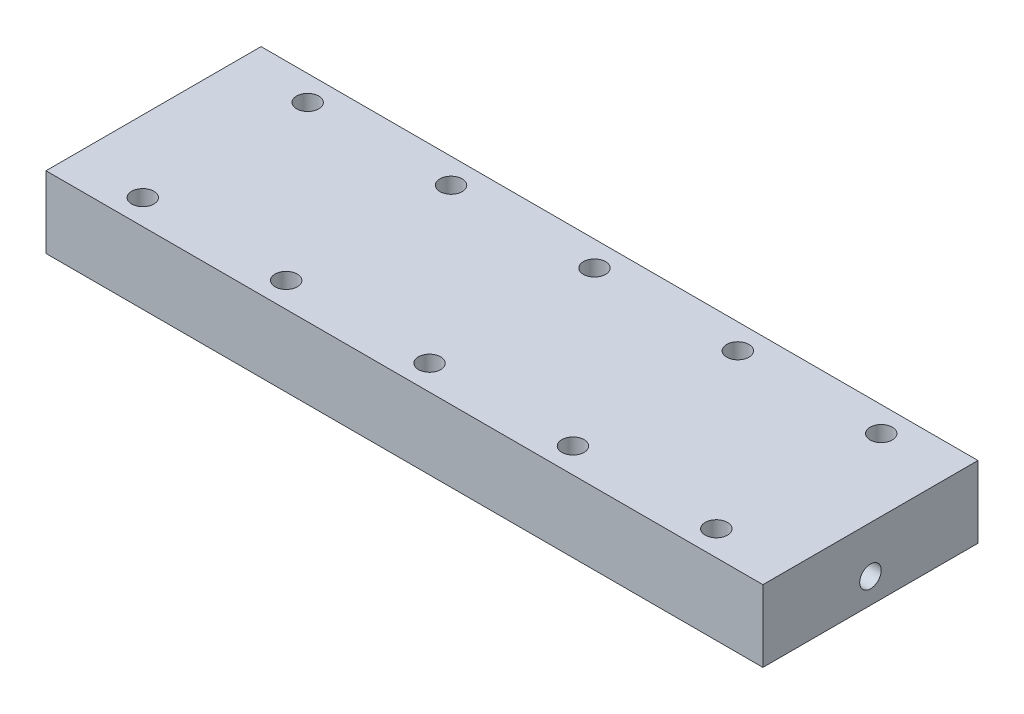
from build123d import *

# Parameters (mm, degrees)
SKETCH1_W               = 100
SKETCH1_H               = 30
BOSS_EXTRUDE1_DEPTH     = 10
SKETCH2_W               = 30
SKETCH2_H               = 18
CUT_EXTRUDE1_DEPTH      = 8.5
CUT_EXTRUDE1_DEPTH_BACK = 8.5
SKETCH4_W               = 10
SKETCH4_H               = 18
BOSS_EXTRUDE2_DEPTH     = 10
REVOLVE1_ANGLE          = 180
REVOLVE2_ANGLE          = 180
REVOLVE3_ANGLE          = 180
SKETCH9_R               = 1
CUT_EXTRUDE2_DEPTH      = 12
SKETCH10_R              = 1.5
CUT_EXTRUDE3_DEPTH      = 12
FILLET3_R               = 1.2
FILLET5_R               = 1.25
FILLET7_R               = 2
SKETCH11_R              = 1.55
CUT_EXTRUDE4_DEPTH      = 20
CUT_EXTRUDE4_DEPTH_BACK = 20


with BuildPart() as part:
    # Sketch1 → Boss-Extrude1 (new body)
    with BuildSketch(Plane(origin=(0, 0, 0), x_dir=(1, 0, 0), z_dir=(0, 1, 0))):
        with Locations((0, 15)):
            Rectangle(SKETCH1_W, SKETCH1_H)
    extrude(amount=BOSS_EXTRUDE1_DEPTH)

    # Sketch2 → Cut-Extrude1 (cut, two sides)
    with BuildSketch(Plane(origin=(0, 0, 0), x_dir=(1, 0, 0), z_dir=(0, 1, 0))) as cut_extrude1_sk:
        with Locations((30, 15)):
            Rectangle(SKETCH2_W, SKETCH2_H)
    extrude(amount=CUT_EXTRUDE1_DEPTH, mode=Mode.SUBTRACT)
    extrude(cut_extrude1_sk.sketch, amount=-CUT_EXTRUDE1_DEPTH_BACK, mode=Mode.SUBTRACT)

    # Sketch4 → Boss-Extrude2 (add)
    with BuildSketch(Plane(origin=(0, 0, 0), x_dir=(1, 0, 0), z_dir=(0, 1, 0))):
        with Locations((20, 15)):
            Rectangle(SKETCH4_W, SKETCH4_H)
    extrude(amount=BOSS_EXTRUDE2_DEPTH)

    # Sketch3 → Cut-Revolve1 (revolve, cut)
    with BuildSketch(Plane(origin=(0, 0, 0), x_dir=(1, 0, 0), z_dir=(0, 1, 0))):
        Polygon((-45, 15), (-45, 8.41), (35, 6.89), (35, 15), align=None)
    revolve(axis=Axis((50, 0, -15), (-1, 0, 0)), mode=Mode.SUBTRACT)

    # Sketch6 → Revolve1 (revolve)
    with BuildSketch(Plane(origin=(0, 0, 0), x_dir=(1, 0, 0), z_dir=(0, 1, 0))):
        Polygon((25, 22.92), (25, 20.42), (15.047727794, 20.23), (15, 22.73), align=None)
    revolve(axis=Axis((-50, 0, -15), (1, 0, 0)), revolution_arc=REVOLVE1_ANGLE)

    # Sketch7 → Revolve2 (revolve)
    with BuildSketch(Plane(origin=(0, 0, 0), x_dir=(1, 0, 0), z_dir=(0, 1, 0))):
        Polygon((-35, 21.78), (-22.5, 22.0175), (-22.5, 19.5175), (-35, 19.28), align=None)
    revolve(axis=Axis((-45, 0, -15), (1, 0, 0)), revolution_arc=REVOLVE2_ANGLE)

    # Sketch8 → Revolve3 (revolve)
    with BuildSketch(Plane(origin=(0, 0, 0), x_dir=(1, 0, 0), z_dir=(0, 1, 0))):
        Polygon((-10, 22.255), (-10, 19.755), (2.5, 19.9925), (2.5, 22.4925), align=None)
    revolve(axis=Axis((-45, 0, -15), (1, 0, 0)), revolution_arc=REVOLVE3_ANGLE)

    # Sketch9 → Cut-Extrude2 (cut)
    with BuildSketch(Plane.ZY.offset(50)):
        with Locations((-15, 3.5)):
            Circle(SKETCH9_R)
    extrude(amount=-CUT_EXTRUDE2_DEPTH, mode=Mode.SUBTRACT)

    # Sketch10 → Cut-Extrude3 (cut)
    with BuildSketch(Plane(origin=(50, 0, 0), x_dir=(0, 0, -1), z_dir=(1, 0, 0))):
        with Locations((15, 3.5)):
            Circle(SKETCH10_R)
    extrude(amount=-CUT_EXTRUDE3_DEPTH, mode=Mode.SUBTRACT)

    # Fillet3
    fillet3_edges = [part.edges().sort_by_distance(p)[0] for p in [
        (15, 7.73, -15),
        (15.047727794, 5.23, -15),
        (-35, 6.78, -15),
        (-22.5, 7.0175, -15),
        (-22.5, 4.5175, -15),
        (-35, 4.28, -15),
        (2.5, 7.4925, -15),
        (-10, 7.255, -15),
        (-10, 4.755, -15),
        (2.5, 4.9925, -15),
    ]]
    fillet(fillet3_edges, radius=FILLET3_R)

    # Fillet5
    fillet5_edges = [part.edges().sort_by_distance(p)[0] for p in [
        (25, 5.42, -15),
    ]]
    fillet(fillet5_edges, radius=FILLET5_R)

    # Fillet7
    fillet7_edges = [part.edges().sort_by_distance(p)[0] for p in [
        (45, 4.25, -24),
        (45, 4.25, -6),
        (35, 8.5, -24),
        (45, 8.5, -15),
        (35, 8.5, -6),
        (25, 8.5, -15),
        (25, 4.25, -6),
        (25, 4.25, -24),
    ]]
    fillet(fillet7_edges, radius=FILLET7_R)

    # Sketch11 → Cut-Extrude4 (cut, two sides)
    with BuildSketch(Plane(origin=(0, 0, 0), x_dir=(1, 0, 0), z_dir=(0, 1, 0))) as cut_extrude4_sk:
        with Locations((-40, 3.5)):
            Circle(SKETCH11_R)
        with Locations((-20, 3.5)):
            Circle(SKETCH11_R)
        with Locations((0, 3.5)):
            Circle(SKETCH11_R)
        with Locations((20, 3.5)):
            Circle(SKETCH11_R)
        with Locations((40, 3.5)):
            Circle(SKETCH11_R)
        with Locations((-40, 26.5)):
            Circle(SKETCH11_R)
        with Locations((-20, 26.5)):
            Circle(SKETCH11_R)
        with Locations((0, 26.5)):
            Circle(SKETCH11_R)
        with Locations((20, 26.5)):
            Circle(SKETCH11_R)
        with Locations((40, 26.5)):
            Circle(SKETCH11_R)
    extrude(amount=CUT_EXTRUDE4_DEPTH, mode=Mode.SUBTRACT)
    extrude(cut_extrude4_sk.sketch, amount=-CUT_EXTRUDE4_DEPTH_BACK, mode=Mode.SUBTRACT)


solid = part.part
